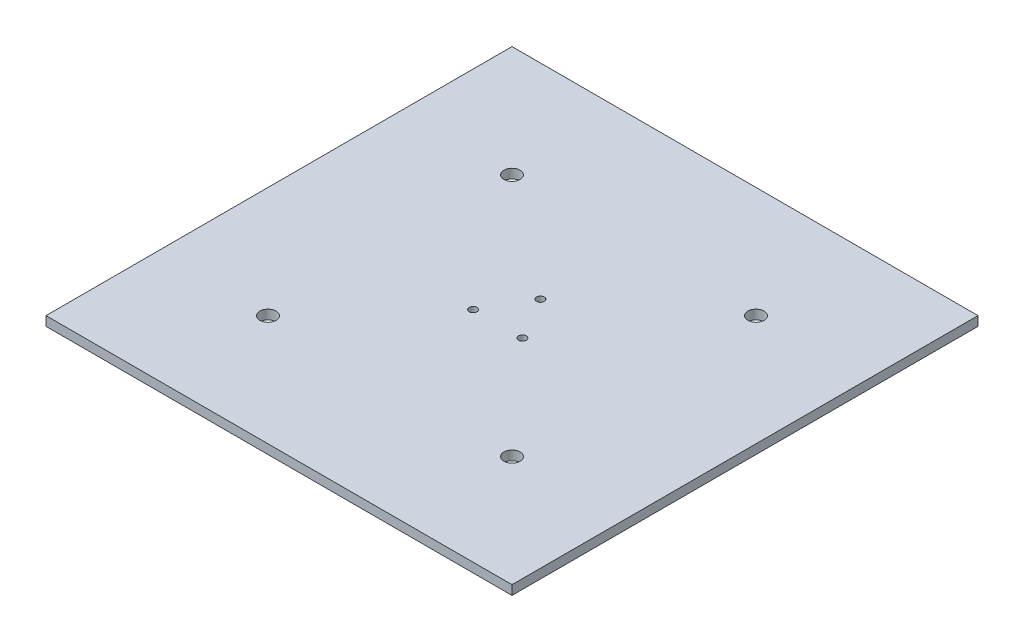
from build123d import *

# Parameters (mm, degrees)
SKETCH1_W           = 254
SKETCH1_H           = 254
BOSS_EXTRUDE1_DEPTH = 5.08
SKETCH2_R           = 2.10058
CUT_EXTRUDE1_DEPTH  = 6.08
SKETCH5_R           = 4.399999963
CUT_EXTRUDE2_DEPTH  = 6.08


with BuildPart() as part:
    # Sketch1 → Boss-Extrude1 (new body)
    with BuildSketch(Plane(origin=(0, 0, 0), x_dir=(1, 0, 0), z_dir=(0, 1, 0))):
        Rectangle(SKETCH1_W, SKETCH1_H)
    extrude(amount=BOSS_EXTRUDE1_DEPTH)

    # Sketch2 → Cut-Extrude1 (cut, through all)
    with BuildSketch(Plane(origin=(0, 5.08, 0), x_dir=(1, 0, 0), z_dir=(0, 1, 0))):
        with Locations((0, 15.499969)):
            Circle(SKETCH2_R)
        with Locations((13.423366912, -7.7499845)):
            Circle(SKETCH2_R)
        with Locations((-13.423366912, -7.7499845)):
            Circle(SKETCH2_R)
    extrude(amount=-CUT_EXTRUDE1_DEPTH, mode=Mode.SUBTRACT)

    # Sketch5 → Cut-Extrude2 (cut, through all)
    with BuildSketch(Plane(origin=(0, 5.08, 0), x_dir=(1, 0, 0), z_dir=(0, 1, 0))):
        with Locations((66.542698013, 66.4572719)):
            Circle(SKETCH5_R)
        with Locations((66.542698013, -66.542698013)):
            Circle(SKETCH5_R)
        with Locations((-66.4572719, -66.542698013)):
            Circle(SKETCH5_R)
        with Locations((-66.4572719, 66.4572719)):
            Circle(SKETCH5_R)
    extrude(amount=-CUT_EXTRUDE2_DEPTH, mode=Mode.SUBTRACT)


solid = part.part
